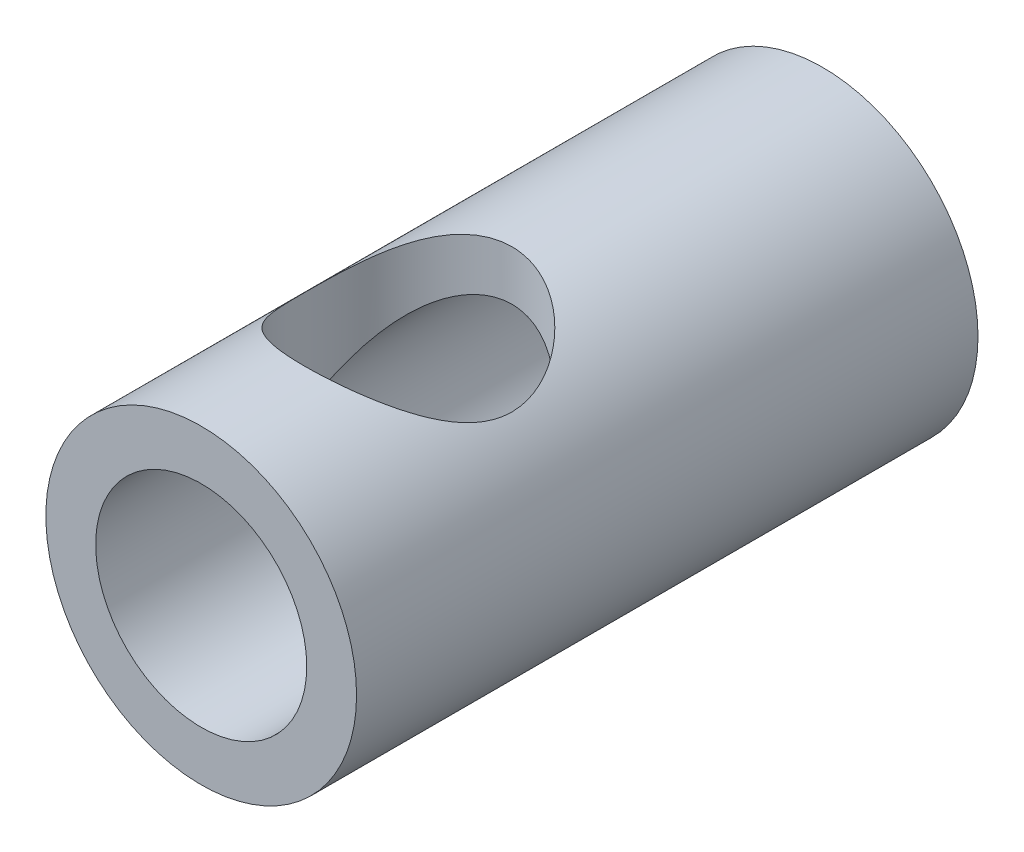
from build123d import *

# Parameters (mm, degrees)
SKETCH1_R           = 3
SKETCH1_R_2         = 2.038096
BOSS_EXTRUDE1_DEPTH = 12
SKETCH2_R           = 2
CUT_EXTRUDE1_DEPTH  = 4


with BuildPart() as part:
    # Sketch1 → Boss-Extrude1 (new body)
    with BuildSketch(Plane.XY):
        Circle(SKETCH1_R)
        Circle(SKETCH1_R_2, mode=Mode.SUBTRACT)
    extrude(amount=BOSS_EXTRUDE1_DEPTH)

    # Sketch2 → Cut-Extrude1 (cut, through all)
    with BuildSketch(Plane(origin=(0, 0, 0), x_dir=(1, 0, 0), z_dir=(0, 1, 0))):
        with Locations((0, -8)):
            Circle(SKETCH2_R)
    extrude(amount=CUT_EXTRUDE1_DEPTH, mode=Mode.SUBTRACT)


solid = part.part
